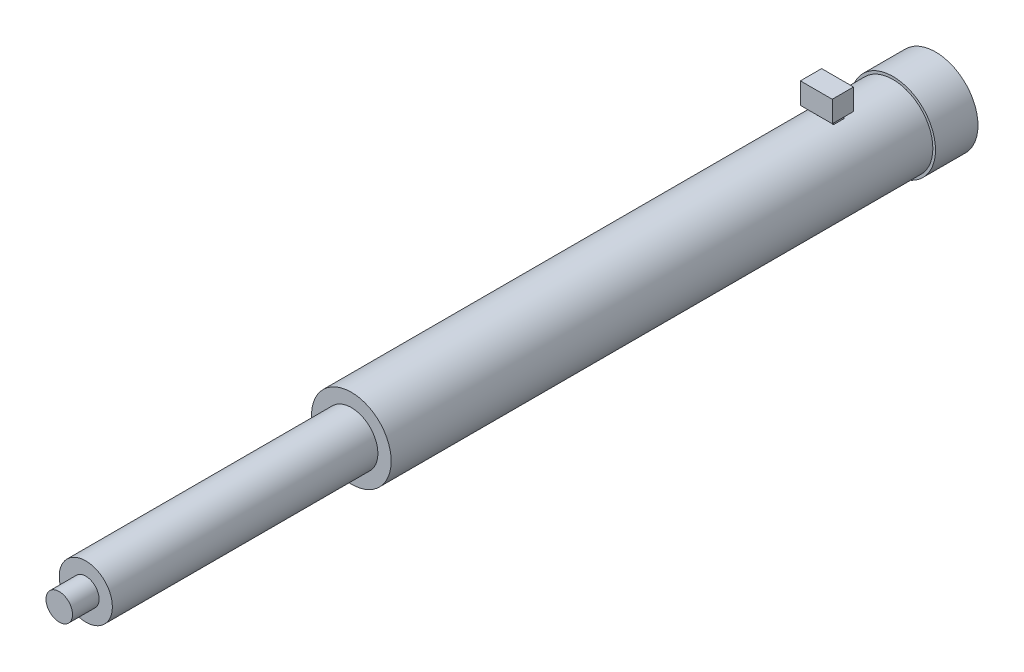
from build123d import *

# Parameters (mm, degrees)
SKETCH2_R            = 10.16
BOSS_EXTRUDE1_DEPTH  = 10.16
SKETCH3_R            = 9.525
BOSS_EXTRUDE2_DEPTH  = 129.54
SKETCH4_R            = 6.35
BOSS_EXTRUDE4_DEPTH  = 63.5
SKETCH5_R            = 3.175
BOSS_EXTRUDE5_DEPTH  = 6.35
SKETCH8_W            = 1.27
SKETCH8_H            = 2.54
EXTRUDE_THIN1_DEPTH  = 8.89
SKETCH9_W            = 7.62
SKETCH9_H            = 5.08
BOSS_EXTRUDE14_DEPTH = 5.08


with BuildPart() as part:
    # Sketch2 → Boss-Extrude1 (new body)
    with BuildSketch(Plane.XY):
        Circle(SKETCH2_R)
    extrude(amount=BOSS_EXTRUDE1_DEPTH)

    # Sketch3 → Boss-Extrude2 (add)
    with BuildSketch(Plane.XY.offset(10.16)):
        Circle(SKETCH3_R)
    extrude(amount=BOSS_EXTRUDE2_DEPTH)

    # Sketch4 → Boss-Extrude4 (add)
    with BuildSketch(Plane.XY.offset(139.7)):
        Circle(SKETCH4_R)
    extrude(amount=BOSS_EXTRUDE4_DEPTH)

    # Sketch5 → Boss-Extrude5 (add)
    with BuildSketch(Plane.XY.offset(203.2)):
        Circle(SKETCH5_R)
    extrude(amount=BOSS_EXTRUDE5_DEPTH)

    # Sketch8 → Extrude-Thin1 (add)
    with BuildSketch(Plane(origin=(0, 2.54, 0), x_dir=(1, 0, 0), z_dir=(0, 1, 0))):
        with Locations((-1.397, -25.185428327)):
            Rectangle(SKETCH8_W, SKETCH8_H)
        with Locations((1.397, -25.185428327)):
            Rectangle(SKETCH8_W, SKETCH8_H)
    extrude(amount=EXTRUDE_THIN1_DEPTH)

    # Sketch9 → Boss-Extrude14 (add)
    with BuildSketch(Plane(origin=(0, 11.43, 0), x_dir=(1, 0, 0), z_dir=(0, 1, 0))):
        with Locations((0, -25.964513942)):
            Rectangle(SKETCH9_W, SKETCH9_H)
    extrude(amount=BOSS_EXTRUDE14_DEPTH)


solid = part.part
